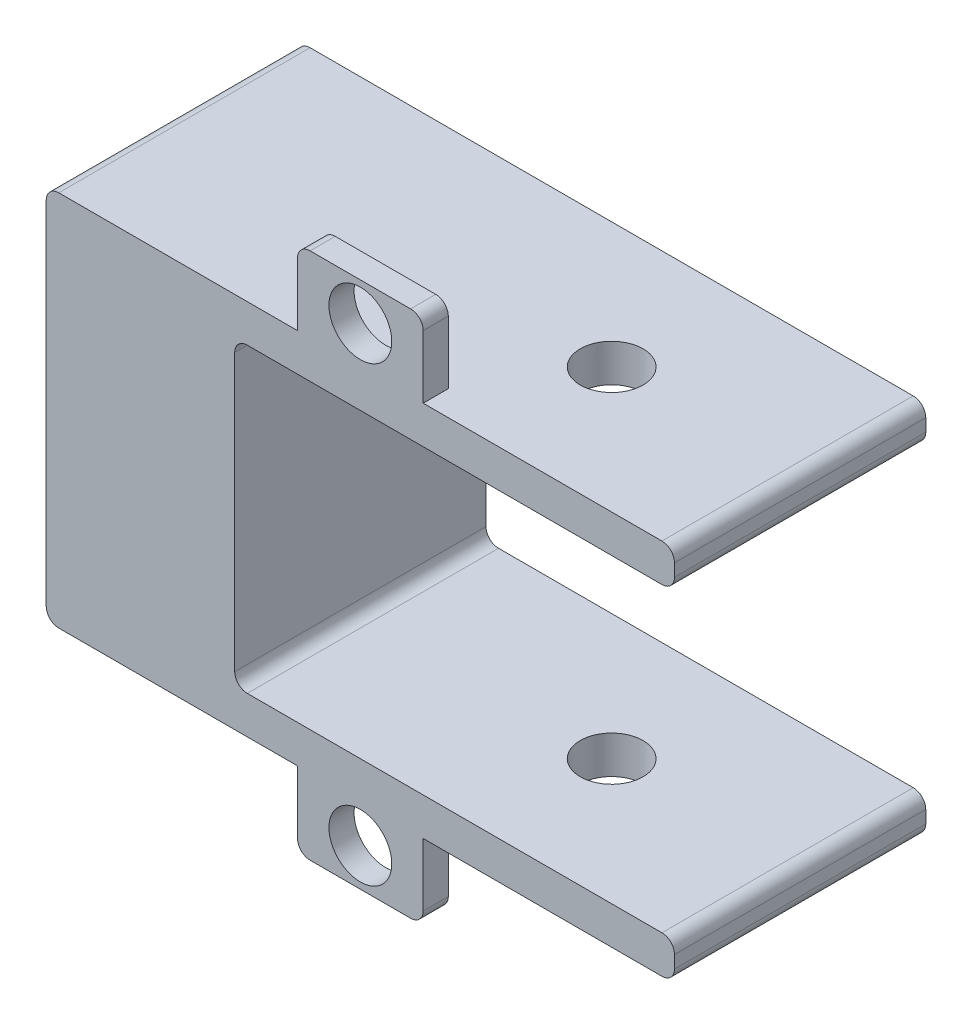
from build123d import *

# Parameters (mm, degrees)
SKETCH1_W           = 63.5
SKETCH1_H           = 38.1
BOSS_EXTRUDE1_DEPTH = 25.4
SKETCH3_W           = 44.45
SKETCH3_H           = 30.48
CUT_EXTRUDE1_DEPTH  = 38.1
SKETCH5_R           = 3.175
CUT_EXTRUDE2_DEPTH  = 76.2
FILLET3_R           = 1.27
SKETCH6_W           = 12.7
SKETCH6_H           = 2.54
BOSS_EXTRUDE2_DEPTH = 7.62
SKETCH7_W           = 12.7
SKETCH7_H           = 2.54
BOSS_EXTRUDE3_DEPTH = 7.62
CUT_EXTRUDE3_REACH  = 4.54
SKETCH8_R           = 3.175
CUT_EXTRUDE4_REACH  = 4.54
SKETCH9_R           = 3.175
FILLET4_R           = 1.27


with BuildPart() as part:
    # Sketch1 → Boss-Extrude1 (new body)
    with BuildSketch(Plane.XY):
        with Locations((31.75, 19.05)):
            Rectangle(SKETCH1_W, SKETCH1_H)
    extrude(amount=BOSS_EXTRUDE1_DEPTH)

    # Sketch3 → Cut-Extrude1 (cut)
    with BuildSketch(Plane(origin=(0, 0, 0), x_dir=(-1, 0, 0), z_dir=(0, 0, -1))):
        with Locations((-41.275, 19.05)):
            Rectangle(SKETCH3_W, SKETCH3_H)
    extrude(amount=-CUT_EXTRUDE1_DEPTH, mode=Mode.SUBTRACT)

    # Sketch5 → Cut-Extrude2 (cut)
    with BuildSketch(Plane.XZ):
        with Locations((44.45, 12.7)):
            Circle(SKETCH5_R)
    extrude(amount=-CUT_EXTRUDE2_DEPTH, mode=Mode.SUBTRACT)

    # Fillet3
    fillet3_edges = [part.edges().sort_by_distance(p)[0] for p in [
        (63.5, 3.81, 12.7),
        (63.5, 34.29, 12.7),
        (19.05, 34.29, 12.7),
        (19.05, 3.81, 12.7),
        (0, 38.1, 12.7),
        (63.5, 38.1, 12.7),
        (63.5, 0, 12.7),
        (0, 0, 12.7),
    ]]
    fillet(fillet3_edges, radius=FILLET3_R)

    # Sketch6 → Boss-Extrude2 (add)
    with BuildSketch(Plane(origin=(0, 38.1, 0), x_dir=(1, 0, 0), z_dir=(0, 1, 0))):
        with Locations((31.75, -24.13)):
            Rectangle(SKETCH6_W, SKETCH6_H)
    extrude(amount=BOSS_EXTRUDE2_DEPTH)

    # Sketch7 → Boss-Extrude3 (add)
    with BuildSketch(Plane.XZ):
        with Locations((31.75, 24.13)):
            Rectangle(SKETCH7_W, SKETCH7_H)
    extrude(amount=BOSS_EXTRUDE3_DEPTH)

    # Sketch8 → Cut-Extrude3 (cut, up to next)
    with BuildSketch(Plane(origin=(0, 0, 22.86), x_dir=(-1, 0, 0), z_dir=(0, 0, -1)), mode=Mode.PRIVATE) as cut_extrude3_sk1:
        with Locations((-31.75, -3.81)):
            Circle(SKETCH8_R)
    cut_extrude3_tool1 = extrude(cut_extrude3_sk1.sketch, amount=-CUT_EXTRUDE3_REACH, mode=Mode.PRIVATE) & part.part
    add(cut_extrude3_tool1.solids().sort_by_distance((31.75, -3.81, 22.86))[0], mode=Mode.SUBTRACT)

    # Sketch9 → Cut-Extrude4 (cut, up to next)
    with BuildSketch(Plane(origin=(0, 0, 22.86), x_dir=(-1, 0, 0), z_dir=(0, 0, -1)), mode=Mode.PRIVATE) as cut_extrude4_sk1:
        with Locations((-31.75, 41.91)):
            Circle(SKETCH9_R)
    cut_extrude4_tool1 = extrude(cut_extrude4_sk1.sketch, amount=-CUT_EXTRUDE4_REACH, mode=Mode.PRIVATE) & part.part
    add(cut_extrude4_tool1.solids().sort_by_distance((31.75, 41.91, 22.86))[0], mode=Mode.SUBTRACT)

    # Fillet4
    fillet4_edges = [part.edges().sort_by_distance(p)[0] for p in [
        (25.4, -7.62, 24.13),
        (38.1, -7.62, 24.13),
        (25.4, 45.72, 24.13),
        (38.1, 45.72, 24.13),
    ]]
    fillet(fillet4_edges, radius=FILLET4_R)


solid = part.part
